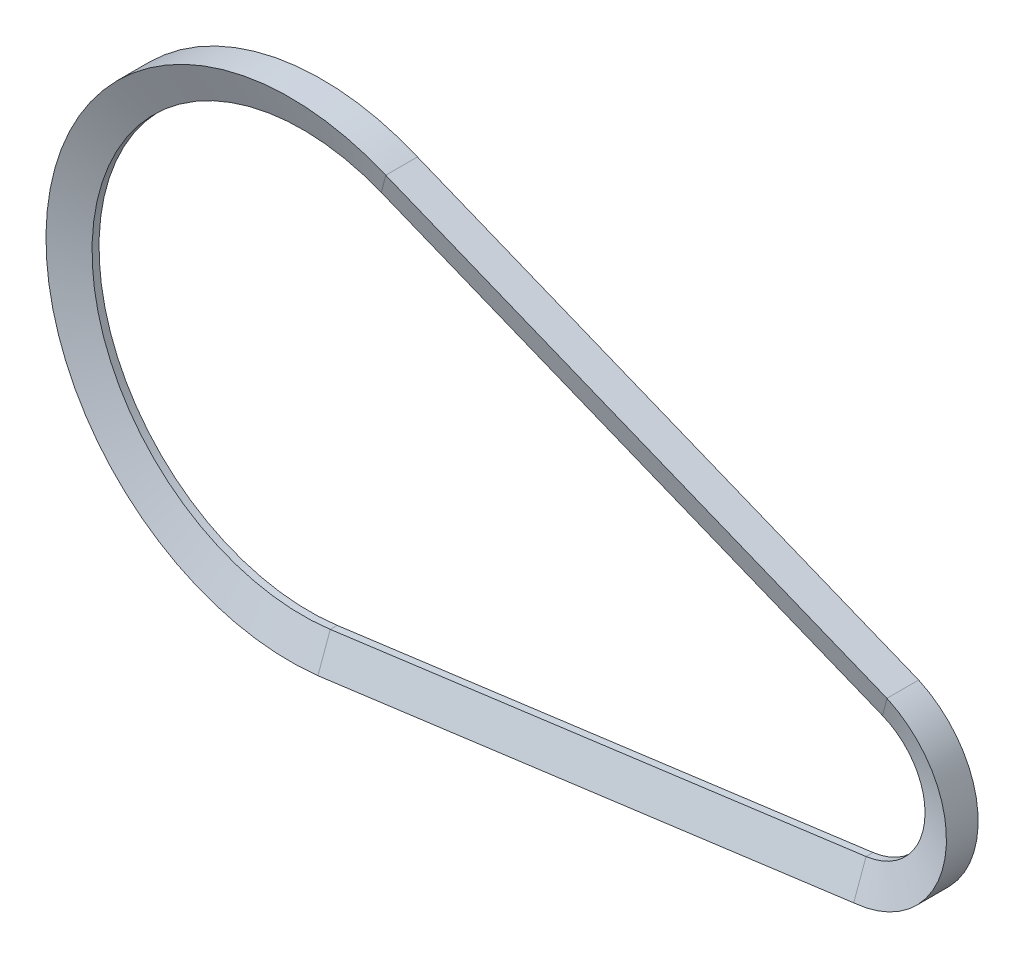
from build123d import *


with BuildPart() as part:
    # Sweep1: sweep along a path in Sketch4
    with BuildLine(Plane.XY) as sweep1_path:
        Line((6.124729851, -46.094876985), (124.475719307, -30.369315156))
        ThreePointArc((124.475719307, -30.369315156), (137.381347861, -17.382946056), (128.117006893, -1.591397138))
        Line((128.117006893, -1.591397138), (17.412721367, 43.116668872))
        ThreePointArc((17.412721367, 43.116668872), (-46.132178368, 5.837132773), (6.124729851, -46.094876985))
    # Sketch5 → Sweep1 (sweep)
    with BuildSketch(Plane(origin=(6.124729851, 0, 0), x_dir=(0, 0, -1), z_dir=(1, 0, 0))):
        Polygon((-0.770223243, -46.094876985), (0.770223243, -46.094876985), (3.5, -53.594876985), (-3.5, -53.594876985), align=None)
    sweep(path=sweep1_path.line)


solid = part.part
